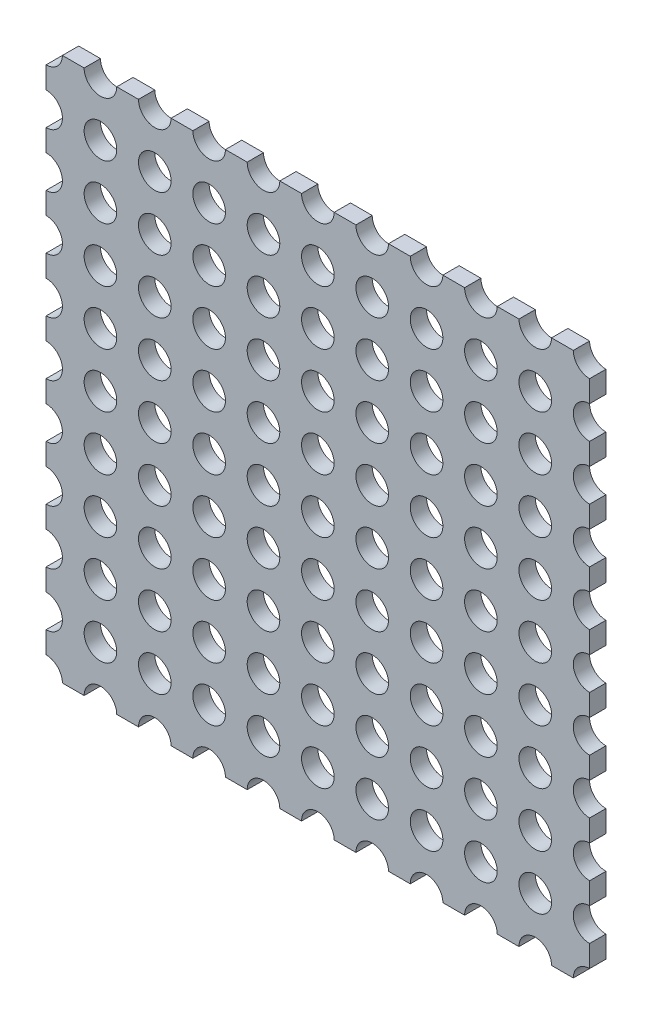
from build123d import *

# Parameters (mm, degrees)
SZKIC1_W                    = 500
SZKIC1_H                    = 500
DODANIE_WYCI_GNI_CIE1_DEPTH = 15
SZKIC2_R                    = 15
WYTNIJ_WYCI_GNI_CIE1_DEPTH  = 15
SZYK_LINIOWY1_COUNT         = 11
SZYK_LINIOWY1_PITCH         = 50
SZYK_LINIOWY1_COUNT_DIR2    = 11
SZYK_LINIOWY1_PITCH_DIR2    = 50


with BuildPart() as part:
    # Szkic1 → Dodanie-wyciągnięcie1 (new body)
    with BuildSketch(Plane.XY):
        Rectangle(SZKIC1_W, SZKIC1_H)
    extrude(amount=DODANIE_WYCI_GNI_CIE1_DEPTH)

    # Szkic2 → Wytnij-wyciągnięcie1 (cut)
    with BuildSketch(Plane.XY):
        with Locations((-250, 250)):
            Circle(SZKIC2_R)
    wytnij_wyci_gni_cie1 = extrude(amount=WYTNIJ_WYCI_GNI_CIE1_DEPTH, mode=Mode.SUBTRACT)

    # Szyk liniowy1: Wytnij-wyci_gni_cie1 11 × 11
    with Locations(*[(i * SZYK_LINIOWY1_PITCH, -j * SZYK_LINIOWY1_PITCH_DIR2, 0) for i in range(SZYK_LINIOWY1_COUNT) for j in range(SZYK_LINIOWY1_COUNT_DIR2) if (i, j) != (0, 0)]):
        add(wytnij_wyci_gni_cie1, mode=Mode.SUBTRACT)


solid = part.part
